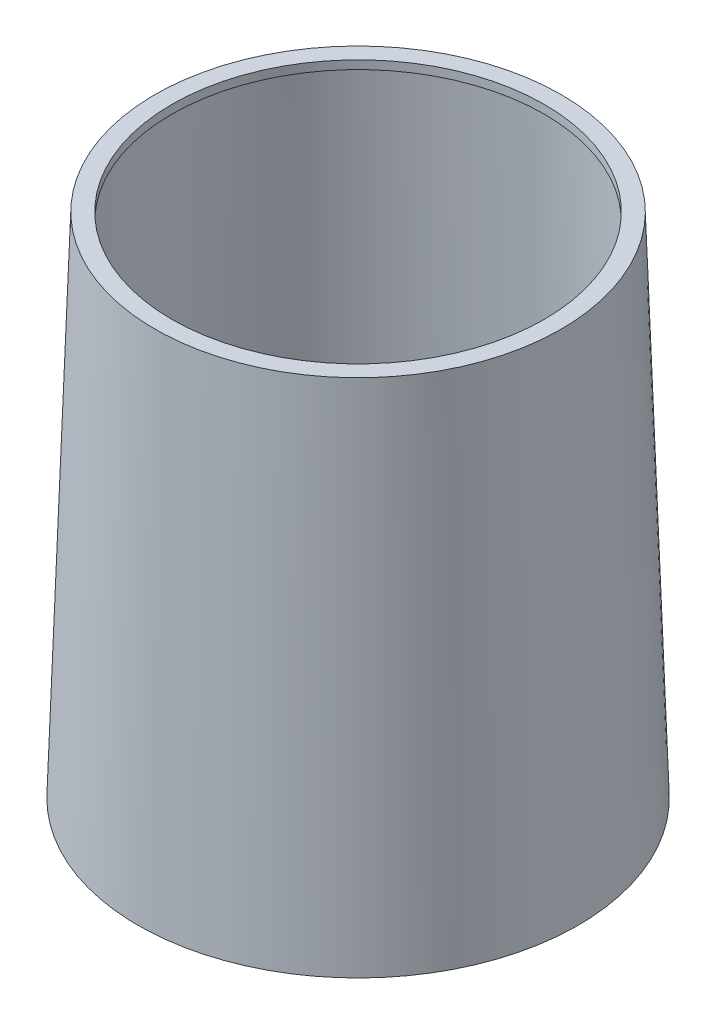
from build123d import *

# Parameters (mm, degrees)
SKETCH6_R          = 11
CUT_EXTRUDE1_DEPTH = 30
SKETCH8_R          = 12.5
SKETCH8_R_2        = 11.5
CUT_EXTRUDE3_DEPTH = 0.5


with BuildPart() as part:
    # Sketch3 → Revolve1 (revolve)
    with BuildSketch(Plane.XY):
        Polygon((0, 0), (13, 0), (12, 30), (0, 30), align=None)
    revolve(axis=Axis((0, 0, 0), (0, 1, 0)))

    # Sketch6 → Cut-Extrude1 (cut)
    with BuildSketch(Plane(origin=(0, 30, 0), x_dir=(1, 0, 0), z_dir=(0, 1, 0))):
        Circle(SKETCH6_R)
    extrude(amount=-CUT_EXTRUDE1_DEPTH, mode=Mode.SUBTRACT)

    # Sketch7 → Cut-Revolve1 (revolve, cut)
    with BuildSketch(Plane.XY):
        Polygon((8.985599586, 29.5), (9.627507592, 0.5), (12.483055633, 0.5), (11.516388966, 29.5), align=None)
    revolve(axis=Axis((0, 0, 0), (0, 1, 0)), mode=Mode.SUBTRACT)

    # Sketch8 → Cut-Extrude3 (cut)
    with BuildSketch(Plane(origin=(0, 0, 0), x_dir=(-1, 0, 0), z_dir=(0, -1, 0))):
        Circle(SKETCH8_R)
        Circle(SKETCH8_R_2, mode=Mode.SUBTRACT)
    extrude(amount=-CUT_EXTRUDE3_DEPTH, mode=Mode.SUBTRACT)


solid = part.part
